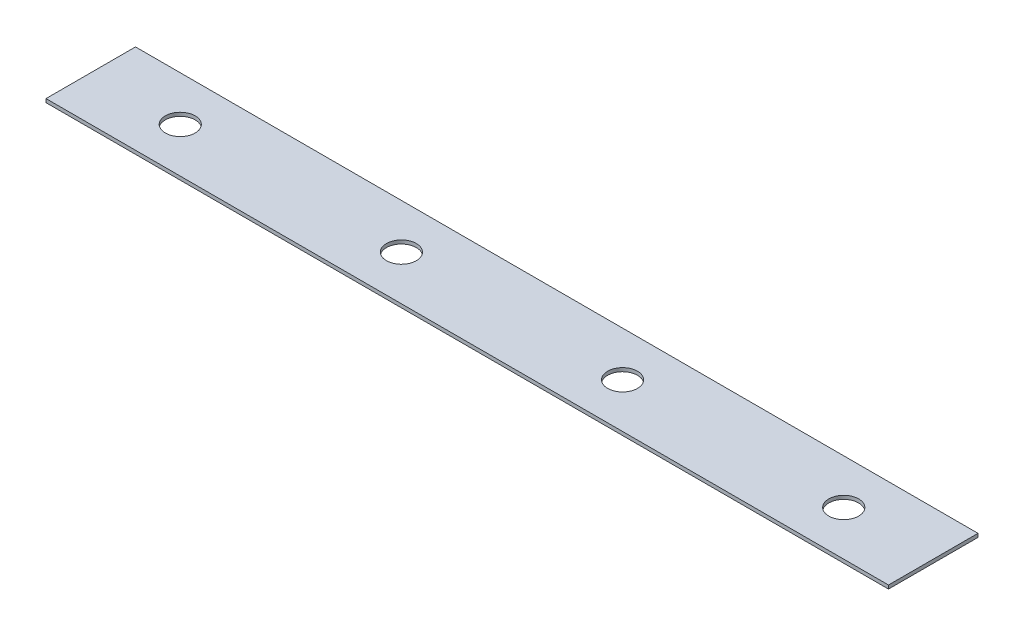
from build123d import *

# Parameters (mm, degrees)
SKETCH1_W           = 38.1
SKETCH1_H           = 1.51892
BOSS_EXTRUDE1_DEPTH = 358.63784
SKETCH3_R           = 6.35
CUT_EXTRUDE1_DEPTH  = 2.51892


with BuildPart() as part:
    # Sketch1 → Boss-Extrude1 (new body)
    with BuildSketch(Plane(origin=(0, 0, 0), x_dir=(0, 0, -1), z_dir=(1, 0, 0))):
        with Locations((19.05, 0.75946)):
            Rectangle(SKETCH1_W, SKETCH1_H)
    extrude(amount=BOSS_EXTRUDE1_DEPTH)

    # Sketch3 → Cut-Extrude1 (cut, through all)
    with BuildSketch(Plane(origin=(0, 1.51892, 0), x_dir=(1, 0, 0), z_dir=(0, 1, 0))):
        with Locations((132.245946667, 19.05)):
            Circle(SKETCH3_R)
        with Locations((226.391893333, 19.05)):
            Circle(SKETCH3_R)
        with Locations((320.53784, 19.05)):
            Circle(SKETCH3_R)
        with Locations((38.1, 19.05)):
            Circle(SKETCH3_R)
    extrude(amount=-CUT_EXTRUDE1_DEPTH, mode=Mode.SUBTRACT)


solid = part.part
